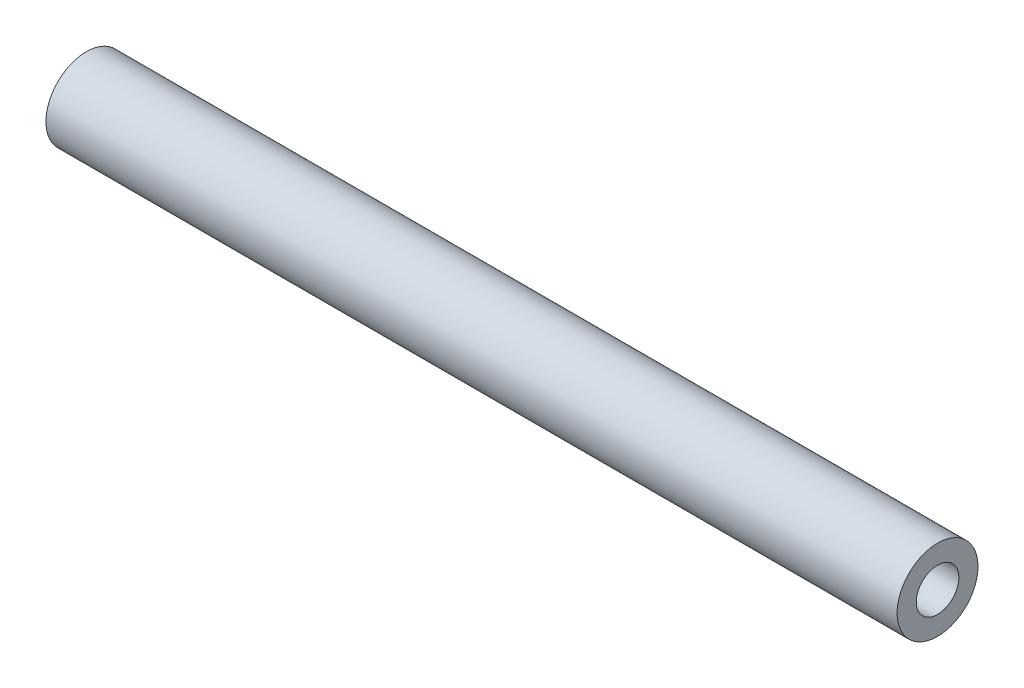
from build123d import *

# Parameters (mm, degrees)
SKETCH1_R                   = 8.001
BOSS_EXTRUDE1_DEPTH         = 168.402
F_3_8_24_TAPPED_HOLE1_D     = 8.4328
F_3_8_24_TAPPED_HOLE1_DEPTH = 22.352
F_3_8_24_TAPPED_HOLE1_TIP   = 2.533468714


with BuildPart() as part:
    # Sketch1 → Boss-Extrude1 (new body)
    with BuildSketch(Plane(origin=(0, 0, 0), x_dir=(0, 0, -1), z_dir=(1, 0, 0))):
        Circle(SKETCH1_R)
    extrude(amount=BOSS_EXTRUDE1_DEPTH)

    # 3/8-24 Tapped Hole1
    with Locations(Plane(origin=(168.402, 0, 0), x_dir=(0, 0, -1), z_dir=(1, 0, 0))):
        with Locations((0, 0)):
            Hole(F_3_8_24_TAPPED_HOLE1_D / 2, depth=F_3_8_24_TAPPED_HOLE1_DEPTH)
            with Locations((0, 0, -(F_3_8_24_TAPPED_HOLE1_DEPTH + F_3_8_24_TAPPED_HOLE1_TIP / 2))):  # 118° drill point
                Cone(0, F_3_8_24_TAPPED_HOLE1_D / 2, F_3_8_24_TAPPED_HOLE1_TIP, mode=Mode.SUBTRACT)


solid = part.part
